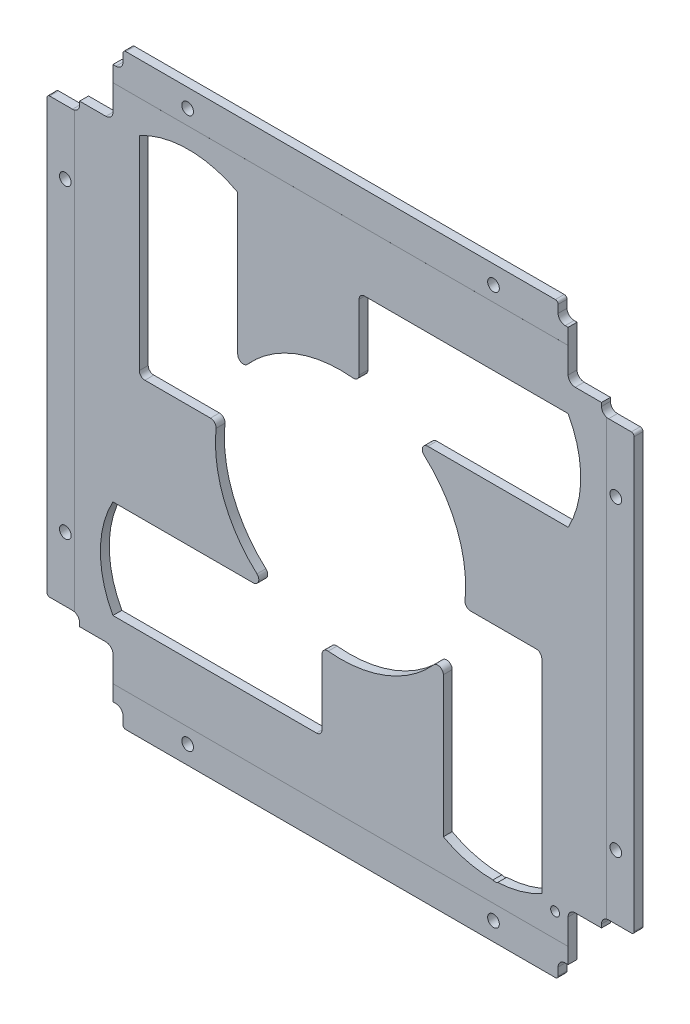
from build123d import *

# Parameters (mm, degrees)
SKETCH1_W                           = 106
SKETCH1_H                           = 106
MAINOUTLINE_DEPTH                   = 1.6
SKETCH4_W                           = 11.7
SKETCH4_H                           = 11.7
RAILCUTOUTS_DEPTH                   = 75.970394157
SKETCH13_W                          = 5.7
SKETCH13_H                          = 1.9
SKETCH13_W_2                        = 1.8
SKETCH13_H_2                        = 3
FILLETCUTOUTS_DEPTH                 = 75.970394157
SMOOTHCORNER_DEPTH                  = 10
MIRROR2_COPY_1_SKETCH_W             = 11.7
MIRROR2_COPY_1_SKETCH_H             = 11.7
MIRROR2_COPY_1_DEPTH                = 75.970394157
MIRROR2_COPY_2_SKETCH_W             = 5.7
MIRROR2_COPY_2_SKETCH_H             = 1.9
MIRROR2_COPY_2_SKETCH_W_2           = 1.8
MIRROR2_COPY_2_SKETCH_H_2           = 3
MIRROR2_COPY_2_DEPTH                = 75.970394157
MIRROR2_COPY_3_DEPTH                = 10
MIRROR2_COPY_4_SKETCH_W             = 11.7
MIRROR2_COPY_4_SKETCH_H             = 11.7
MIRROR2_COPY_4_DEPTH                = 75.970394157
MIRROR2_COPY_5_SKETCH_W             = 5.7
MIRROR2_COPY_5_SKETCH_H             = 1.9
MIRROR2_COPY_5_SKETCH_W_2           = 1.8
MIRROR2_COPY_5_SKETCH_H_2           = 3
MIRROR2_COPY_5_DEPTH                = 75.970394157
MIRROR2_COPY_6_DEPTH                = 10
M2_CLEARANCE_HOLE1_D                = 2.1
INTERBOARDCONNECTORHOLES_DEPTH      = 75.970394157
INTERBOARDCONNECTORHOLES_DEPTH_BACK = 75.970394157
SKETCH12_R                          = 0.8
SKETCH16_W                          = 90
SKETCH16_H                          = 6.2
SKETCH16_W_2                        = 5.2
SKETCH16_H_2                        = 90
CUT_EXTRUDE6_DEPTH                  = 0.001
CUT_EXTRUDE10_DEPTH                 = 75.970394157
CUT_EXTRUDE10_DEPTH_BACK            = 75.970394157
SKETCH21_R                          = 22.5
F_2U_TURNSTILE_CUTOUT_REACH         = 76.97
SKETCH24_OUTSIDE_W                  = 137.984
SKETCH24_OUTSIDE_H                  = 137.984
SKETCH24_OUTSIDE_W_2                = 105.6
SKETCH24_OUTSIDE_H_2                = 105.6
CUT_EXTRUDE19_DEPTH                 = 75.970394157
FILLET7_R                           = 0.5
FILLET8_R                           = 1


with BuildPart() as part:
    # Sketch1 → mainOutline (new body)
    with BuildSketch(Plane.XY):
        Rectangle(SKETCH1_W, SKETCH1_H)
    extrude(amount=MAINOUTLINE_DEPTH)

    # Sketch4 → railCutouts (cut, through all)
    with BuildSketch(Plane(origin=(0, 0, 0), x_dir=(-1, 0, 0), z_dir=(0, 0, -1))):
        with Locations((47.15, 47.15)):
            Rectangle(SKETCH4_W, SKETCH4_H)
    railcutouts = extrude(amount=-RAILCUTOUTS_DEPTH, mode=Mode.SUBTRACT)

    # Sketch13 → filletCutouts (cut, symmetric)
    with BuildSketch(Plane(origin=(0, 0, 0), x_dir=(-1, 0, 0), z_dir=(0, 0, -1))):
        with Locations((50.15, 40.35)):
            Rectangle(SKETCH13_W, SKETCH13_H)
        with Locations((40.4, 51.5)):
            Rectangle(SKETCH13_W_2, SKETCH13_H_2)
    filletcutouts = extrude(amount=FILLETCUTOUTS_DEPTH, both=True, mode=Mode.SUBTRACT)

    # Sketch27 → smoothCorner (cut)
    with BuildSketch(Plane.XY.offset(1.6)):
        with BuildLine():
            Line((-40.928025612, 42.198025612), (-40.928025612, 49.628025612))
            Line((-40.928025612, 49.628025612), (-40.398025612, 49.628025612))
            ThreePointArc((-40.398025612, 49.628025612), (-39.5, 50), (-39.128025612, 50.898025612))
            Line((-39.128025612, 50.898025612), (-39.128025612, 53))
            Line((-39.128025612, 53), (-53, 53))
            Line((-53, 53), (-53, 39.028025612))
            Line((-53, 39.028025612), (-48.198025612, 39.028025612))
            ThreePointArc((-48.198025612, 39.028025612), (-47.3, 39.4), (-46.928025612, 40.298025612))
            Line((-46.928025612, 40.298025612), (-46.928025612, 40.928025612))
            Line((-46.928025612, 40.928025612), (-42.198025612, 40.928025612))
            ThreePointArc((-42.198025612, 40.928025612), (-41.3, 41.3), (-40.928025612, 42.198025612))
        make_face()
    smoothcorner = extrude(amount=-SMOOTHCORNER_DEPTH, mode=Mode.SUBTRACT)

    # Mirror1: railCutouts, filletCutouts, smoothCorner across plane
    add(railcutouts.mirror(Plane(origin=(0, 0, 0), x_dir=(0, 0, 1), z_dir=(1, 0, 0))), mode=Mode.SUBTRACT)
    add(filletcutouts.mirror(Plane(origin=(0, 0, 0), x_dir=(0, 0, 1), z_dir=(1, 0, 0))), mode=Mode.SUBTRACT)
    add(smoothcorner.mirror(Plane(origin=(0, 0, 0), x_dir=(0, 0, 1), z_dir=(1, 0, 0))), mode=Mode.SUBTRACT)

    # Mirror2 copy 1 sketch → Mirror2 copy 1 (cut, through all)
    with BuildSketch(Plane(origin=(0, 0, 0), x_dir=(1, 0, 0), z_dir=(0, 0, -1))):
        with Locations((47.15, 47.15)):
            Rectangle(MIRROR2_COPY_1_SKETCH_W, MIRROR2_COPY_1_SKETCH_H)
    extrude(amount=-MIRROR2_COPY_1_DEPTH, mode=Mode.SUBTRACT)

    # Mirror2 copy 2 sketch → Mirror2 copy 2 (cut, symmetric)
    with BuildSketch(Plane(origin=(0, 0, 0), x_dir=(1, 0, 0), z_dir=(0, 0, -1))):
        with Locations((50.15, 40.35)):
            Rectangle(MIRROR2_COPY_2_SKETCH_W, MIRROR2_COPY_2_SKETCH_H)
        with Locations((40.4, 51.5)):
            Rectangle(MIRROR2_COPY_2_SKETCH_W_2, MIRROR2_COPY_2_SKETCH_H_2)
    extrude(amount=MIRROR2_COPY_2_DEPTH, both=True, mode=Mode.SUBTRACT)

    # Mirror2 copy 3 sketch → Mirror2 copy 3 (cut)
    with BuildSketch(Plane(origin=(0, 0, 1.6), x_dir=(-1, 0, 0), z_dir=(0, 0, 1))):
        with BuildLine():
            Line((-40.928025612, 42.198025612), (-40.928025612, 49.628025612))
            Line((-40.928025612, 49.628025612), (-40.398025612, 49.628025612))
            ThreePointArc((-40.398025612, 49.628025612), (-39.5, 50), (-39.128025612, 50.898025612))
            Line((-39.128025612, 50.898025612), (-39.128025612, 53))
            Line((-39.128025612, 53), (-53, 53))
            Line((-53, 53), (-53, 39.028025612))
            Line((-53, 39.028025612), (-48.198025612, 39.028025612))
            ThreePointArc((-48.198025612, 39.028025612), (-47.3, 39.4), (-46.928025612, 40.298025612))
            Line((-46.928025612, 40.298025612), (-46.928025612, 40.928025612))
            Line((-46.928025612, 40.928025612), (-42.198025612, 40.928025612))
            ThreePointArc((-42.198025612, 40.928025612), (-41.3, 41.3), (-40.928025612, 42.198025612))
        make_face()
    extrude(amount=-MIRROR2_COPY_3_DEPTH, mode=Mode.SUBTRACT)

    # Mirror2 copy 4 sketch → Mirror2 copy 4 (cut, through all)
    with BuildSketch(Plane(origin=(0, 0, 0), x_dir=(-1, 0, 0), z_dir=(0, 0, -1))):
        with Locations((47.15, -47.15)):
            Rectangle(MIRROR2_COPY_4_SKETCH_W, MIRROR2_COPY_4_SKETCH_H)
    extrude(amount=-MIRROR2_COPY_4_DEPTH, mode=Mode.SUBTRACT)

    # Mirror2 copy 5 sketch → Mirror2 copy 5 (cut, symmetric)
    with BuildSketch(Plane(origin=(0, 0, 0), x_dir=(-1, 0, 0), z_dir=(0, 0, -1))):
        with Locations((50.15, -40.35)):
            Rectangle(MIRROR2_COPY_5_SKETCH_W, MIRROR2_COPY_5_SKETCH_H)
        with Locations((40.4, -51.5)):
            Rectangle(MIRROR2_COPY_5_SKETCH_W_2, MIRROR2_COPY_5_SKETCH_H_2)
    extrude(amount=MIRROR2_COPY_5_DEPTH, both=True, mode=Mode.SUBTRACT)

    # Mirror2 copy 6 sketch → Mirror2 copy 6 (cut)
    with BuildSketch(Plane.XY.offset(1.6)):
        with BuildLine():
            Line((-40.928025612, -42.198025612), (-40.928025612, -49.628025612))
            Line((-40.928025612, -49.628025612), (-40.398025612, -49.628025612))
            ThreePointArc((-40.398025612, -49.628025612), (-39.5, -50), (-39.128025612, -50.898025612))
            Line((-39.128025612, -50.898025612), (-39.128025612, -53))
            Line((-39.128025612, -53), (-53, -53))
            Line((-53, -53), (-53, -39.028025612))
            Line((-53, -39.028025612), (-48.198025612, -39.028025612))
            ThreePointArc((-48.198025612, -39.028025612), (-47.3, -39.4), (-46.928025612, -40.298025612))
            Line((-46.928025612, -40.298025612), (-46.928025612, -40.928025612))
            Line((-46.928025612, -40.928025612), (-42.198025612, -40.928025612))
            ThreePointArc((-42.198025612, -40.928025612), (-41.3, -41.3), (-40.928025612, -42.198025612))
        make_face()
    extrude(amount=-MIRROR2_COPY_6_DEPTH, mode=Mode.SUBTRACT)

    # M2 Clearance Hole1 (through all)
    with Locations(Plane(origin=(0, 0, 0), x_dir=(-1, 0, 0), z_dir=(0, 0, -1))):
        with Locations((49.5, -27.5), (27.5, -49.5), (-49.5, -27.5), (-27.5, -49.5), (-27.5, 49.5), (-49.5, 27.5), (27.5, 49.5), (49.5, 27.5)):
            Hole(M2_CLEARANCE_HOLE1_D / 2)

    # Sketch12 → interboardConnectorHoles (cut, two sides: drawn at the far end of the back side and taken through both)
    with BuildSketch(Plane.XY.offset(1.6).offset(-INTERBOARDCONNECTORHOLES_DEPTH_BACK)):
        with Locations((27.815, -42.5)):
            Circle(SKETCH12_R)
        with Locations((38.585, -42.5)):
            Circle(SKETCH12_R)
    extrude(amount=INTERBOARDCONNECTORHOLES_DEPTH + INTERBOARDCONNECTORHOLES_DEPTH_BACK, mode=Mode.SUBTRACT)

    # Sketch16 → Cut-Extrude6 (cut)
    with BuildSketch(Plane.XY.offset(1.6)):
        with Locations((0, -49.9)):
            Rectangle(SKETCH16_W, SKETCH16_H)
        with Locations((0, 49.9)):
            Rectangle(SKETCH16_W, SKETCH16_H)
        with Locations((-50.4, 0)):
            Rectangle(SKETCH16_W_2, SKETCH16_H_2)
        with Locations((50.4, 0)):
            Rectangle(SKETCH16_W_2, SKETCH16_H_2)
    extrude(amount=-CUT_EXTRUDE6_DEPTH, mode=Mode.SUBTRACT)

    # Sketch21 → Cut-Extrude10 (cut, two sides: drawn at the far end of the back side and taken through both)
    with BuildSketch(Plane.XY.offset(-CUT_EXTRUDE10_DEPTH_BACK)):
        Circle(SKETCH21_R)
    extrude(amount=CUT_EXTRUDE10_DEPTH + CUT_EXTRUDE10_DEPTH_BACK, mode=Mode.SUBTRACT)

    # Sketch25 → 2U turnstile cutout (cut, up to next)
    with BuildSketch(Plane(origin=(0, 0, 0), x_dir=(-1, 0, 0), z_dir=(0, 0, -1)), mode=Mode.PRIVATE) as f_2u_turnstile_cutout_sk1:
        with BuildLine():
            Line((40.937273383, -36.1866), (3.332, -36.1866))
            Line((3.332, -36.1866), (3.332, -18.4866))
            Line((3.332, -18.4866), (40.937273383, -18.4866))
            ThreePointArc((40.937273383, -18.4866), (43.19142776, -27.3366), (40.937273383, -36.1866))
        make_face()
    f_2u_turnstile_cutout_tool1 = extrude(f_2u_turnstile_cutout_sk1.sketch, amount=-F_2U_TURNSTILE_CUTOUT_REACH, mode=Mode.PRIVATE) & part.part
    # Sketch25 → 2U turnstile cutout (cut, up to next)
    with BuildSketch(Plane(origin=(0, 0, 0), x_dir=(-1, 0, 0), z_dir=(0, 0, -1)), mode=Mode.PRIVATE) as f_2u_turnstile_cutout_sk2:
        with BuildLine():
            Line((-18.4866, -3.332), (-18.4866, -40.937273383))
            ThreePointArc((-18.4866, -40.937273383), (-27.3366, -43.19142776), (-36.1866, -40.937273383))
            Line((-36.1866, -40.937273383), (-36.1866, -3.332))
            Line((-36.1866, -3.332), (-18.4866, -3.332))
        make_face()
    f_2u_turnstile_cutout_tool2 = extrude(f_2u_turnstile_cutout_sk2.sketch, amount=-F_2U_TURNSTILE_CUTOUT_REACH, mode=Mode.PRIVATE) & part.part
    # Sketch25 → 2U turnstile cutout (cut, up to next)
    with BuildSketch(Plane(origin=(0, 0, 0), x_dir=(-1, 0, 0), z_dir=(0, 0, -1)), mode=Mode.PRIVATE) as f_2u_turnstile_cutout_sk3:
        with BuildLine():
            Line((-3.332, 18.4866), (-40.937273383, 18.4866))
            ThreePointArc((-40.937273383, 18.4866), (-43.19142776, 27.3366), (-40.937273383, 36.1866))
            Line((-40.937273383, 36.1866), (-3.332, 36.1866))
            Line((-3.332, 36.1866), (-3.332, 18.4866))
        make_face()
    f_2u_turnstile_cutout_tool3 = extrude(f_2u_turnstile_cutout_sk3.sketch, amount=-F_2U_TURNSTILE_CUTOUT_REACH, mode=Mode.PRIVATE) & part.part
    # Sketch25 → 2U turnstile cutout (cut, up to next)
    with BuildSketch(Plane(origin=(0, 0, 0), x_dir=(-1, 0, 0), z_dir=(0, 0, -1)), mode=Mode.PRIVATE) as f_2u_turnstile_cutout_sk4:
        with BuildLine():
            Line((18.4866, 3.332), (18.4866, 40.937273383))
            ThreePointArc((18.4866, 40.937273383), (27.3366, 43.19142776), (36.1866, 40.937273383))
            Line((36.1866, 40.937273383), (36.1866, 3.332))
            Line((36.1866, 3.332), (18.4866, 3.332))
        make_face()
    f_2u_turnstile_cutout_tool4 = extrude(f_2u_turnstile_cutout_sk4.sketch, amount=-F_2U_TURNSTILE_CUTOUT_REACH, mode=Mode.PRIVATE) & part.part
    add(f_2u_turnstile_cutout_tool1.solids().sort_by_distance((-22.901342, -27.3366, 0))[0], mode=Mode.SUBTRACT)
    add(f_2u_turnstile_cutout_tool2.solids().sort_by_distance((27.3366, -22.901342, 0))[0], mode=Mode.SUBTRACT)
    add(f_2u_turnstile_cutout_tool3.solids().sort_by_distance((22.901342, 27.3366, 0))[0], mode=Mode.SUBTRACT)
    add(f_2u_turnstile_cutout_tool4.solids().sort_by_distance((-27.3366, 22.901342, 0))[0], mode=Mode.SUBTRACT)

    # Sketch24 outside → Cut-Extrude19 (cut, through all)
    with BuildSketch(Plane.XY.offset(1.6)):
        Rectangle(SKETCH24_OUTSIDE_W, SKETCH24_OUTSIDE_H)
        Rectangle(SKETCH24_OUTSIDE_W_2, SKETCH24_OUTSIDE_H_2, mode=Mode.SUBTRACT)
    extrude(amount=-CUT_EXTRUDE19_DEPTH, mode=Mode.SUBTRACT)

    # Fillet7
    fillet7_edges = [part.edges().sort_by_distance(p)[0] for p in [
        (-52.8, -39.028025612, 0.7995),
        (-39.128025612, -52.8, 0.7995),
        (39.128025612, -52.8, 0.7995),
        (52.8, -39.028025612, 0.7995),
        (52.8, 39.028025612, 0.7995),
        (39.128025612, 52.8, 0.7995),
        (-39.128025612, 52.8, 0.7995),
        (-52.8, 39.028025612, 0.7995),
    ]]
    fillet(fillet7_edges, radius=FILLET7_R)

    # Fillet8
    fillet8_edges = [part.edges().sort_by_distance(p)[0] for p in [
        (-3.332, -36.1866, 0.8),
        (-18.4866, 12.825584604, 0.8),
        (-36.1866, 3.332, 0.8),
        (-22.251916232, 3.332, 0.8),
        (-12.825584604, -18.4866, 0.8),
        (-3.332, -22.251916232, 0.8),
        (18.4866, -12.825584604, 0.8),
        (36.1866, -3.332, 0.8),
        (22.251916232, -3.332, 0.8),
        (12.825584604, 18.4866, 0.8),
        (3.332, 22.251916232, 0.8),
        (3.332, 36.1866, 0.8),
    ]]
    fillet(fillet8_edges, radius=FILLET8_R)


solid = part.part
